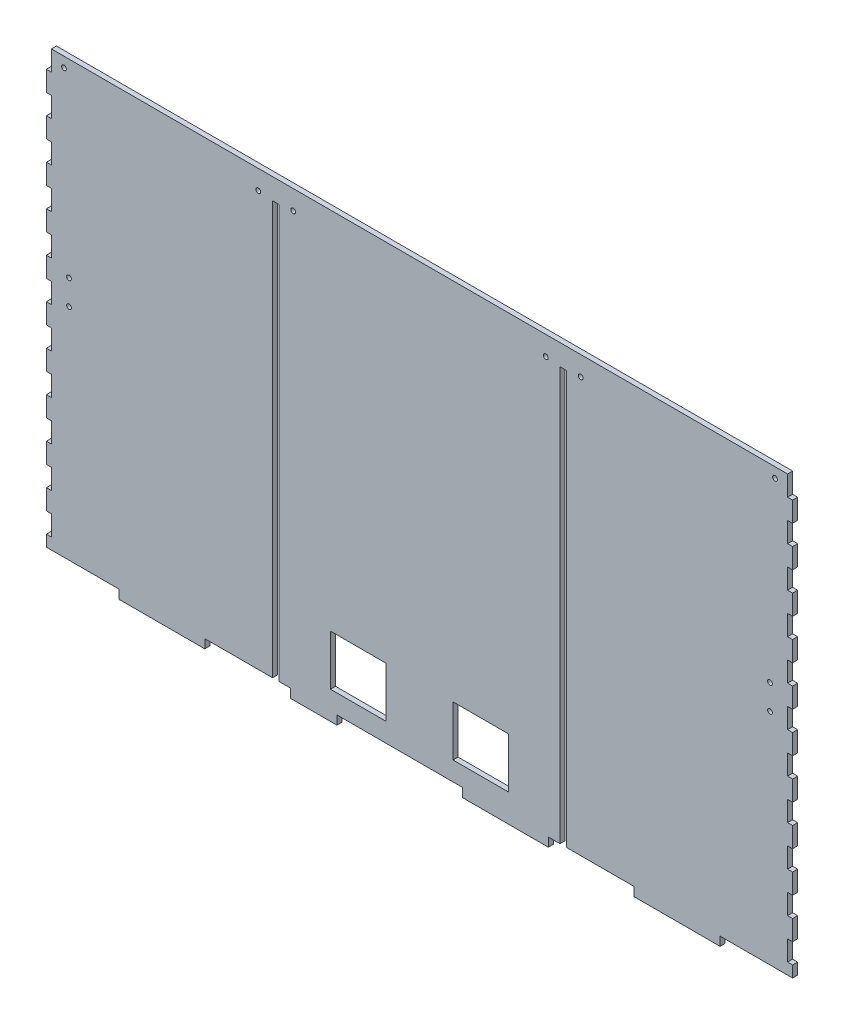
from build123d import *

# Parameters (mm, degrees)
SKETCH1_W                    = 3.175
SKETCH1_H                    = 12.7
MAIN_EXTRUDE_DEPTH           = 3.175
SKETCH8_R                    = 1.5
SKETCH8_W                    = 3.175
SKETCH8_H                    = 31.877
MOUNT_HOLES_DEPTH            = 4.175
SKETCH3_W                    = 4
SKETCH3_H                    = 260.604
DOOR_SLOTS_DEPTH             = 10
SKETCH10_R                   = 1.5
DOOR_GUIDE_MOUNT_HOLES_DEPTH = 4.175
SKETCH12_R                   = 1.5
EXTENSION_CLIP_HOLES_DEPTH   = 4.175
EXTENSION_CENTER_CUT_DEPTH   = 4.175
SKETCH17_W                   = 35
SKETCH17_H                   = 31.75
SKETCH17_W_2                 = 24.976666667
SKETCH17_H_2                 = 5.588
NOSEPOKEHOLES_DEPTH          = 10


with BuildPart() as part:
    # Sketch1 → Main Extrude (new body)
    with BuildSketch(Plane.XY):
        Polygon((-243.84, -134.112), (-189.653333333, -134.112), (-189.653333333, -139.7), (-135.466666667, -139.7), (-135.466666667, -134.112), (-81.28, -134.112), (-81.28, -139.7), (-27.093333333, -139.7), (-27.093333333, -134.112), (27.093333333, -134.112), (27.093333333, -139.7), (81.28, -139.7), (81.28, -134.112), (135.466666667, -134.112), (135.466666667, -139.7), (189.653333333, -139.7), (189.653333333, -134.112), (243.84, -134.112), (243.84, -139.7), (298.026666667, -139.7), (298.026666667, -134.112), (352.213333333, -134.112), (352.213333333, -139.7), (406.4, -139.7), (406.4, 139.7), (381, 139.7), (381, 127), (377.825, 127), (377.825, 139.7), (-377.825, 139.7), (-377.825, 127), (-381, 127), (-381, 139.7), (-406.4, 139.7), (-406.4, -139.7), (-352.213333333, -139.7), (-352.213333333, -134.112), (-298.026666667, -134.112), (-298.026666667, -139.7), (-243.84, -139.7), align=None)
        with Locations((-379.4125, -120.65)):
            Rectangle(SKETCH1_W, SKETCH1_H, mode=Mode.SUBTRACT)
        with Locations((-379.4125, -95.25)):
            Rectangle(SKETCH1_W, SKETCH1_H, mode=Mode.SUBTRACT)
        with Locations((379.4125, 82.55)):
            Rectangle(SKETCH1_W, SKETCH1_H, mode=Mode.SUBTRACT)
        with Locations((379.4125, 57.15)):
            Rectangle(SKETCH1_W, SKETCH1_H, mode=Mode.SUBTRACT)
        with Locations((379.4125, 31.75)):
            Rectangle(SKETCH1_W, SKETCH1_H, mode=Mode.SUBTRACT)
        with Locations((379.4125, 6.35)):
            Rectangle(SKETCH1_W, SKETCH1_H, mode=Mode.SUBTRACT)
        with Locations((379.4125, -19.05)):
            Rectangle(SKETCH1_W, SKETCH1_H, mode=Mode.SUBTRACT)
        with Locations((379.4125, -44.45)):
            Rectangle(SKETCH1_W, SKETCH1_H, mode=Mode.SUBTRACT)
        with Locations((379.4125, -69.85)):
            Rectangle(SKETCH1_W, SKETCH1_H, mode=Mode.SUBTRACT)
        with Locations((379.4125, -95.25)):
            Rectangle(SKETCH1_W, SKETCH1_H, mode=Mode.SUBTRACT)
        with Locations((379.4125, -120.65)):
            Rectangle(SKETCH1_W, SKETCH1_H, mode=Mode.SUBTRACT)
        with Locations((-379.4125, -69.85)):
            Rectangle(SKETCH1_W, SKETCH1_H, mode=Mode.SUBTRACT)
        with Locations((-379.4125, -44.45)):
            Rectangle(SKETCH1_W, SKETCH1_H, mode=Mode.SUBTRACT)
        with Locations((-379.4125, -19.05)):
            Rectangle(SKETCH1_W, SKETCH1_H, mode=Mode.SUBTRACT)
        with Locations((-379.4125, 6.35)):
            Rectangle(SKETCH1_W, SKETCH1_H, mode=Mode.SUBTRACT)
        with Locations((-379.4125, 31.75)):
            Rectangle(SKETCH1_W, SKETCH1_H, mode=Mode.SUBTRACT)
        with Locations((-379.4125, 57.15)):
            Rectangle(SKETCH1_W, SKETCH1_H, mode=Mode.SUBTRACT)
        with Locations((-379.4125, 82.55)):
            Rectangle(SKETCH1_W, SKETCH1_H, mode=Mode.SUBTRACT)
        with Locations((-379.4125, 107.95)):
            Rectangle(SKETCH1_W, SKETCH1_H, mode=Mode.SUBTRACT)
        with Locations((379.4125, 107.95)):
            Rectangle(SKETCH1_W, SKETCH1_H, mode=Mode.SUBTRACT)
    extrude(amount=MAIN_EXTRUDE_DEPTH)

    # Sketch8 → Mount Holes (cut, through all)
    with BuildSketch(Plane.XY.offset(3.175)):
        with Locations((-393.7, -120.65)):
            Circle(SKETCH8_R)
        with Locations((393.7, -120.65)):
            Circle(SKETCH8_R)
        with Locations((-382.5875, 12.319)):
            Rectangle(SKETCH8_W, SKETCH8_H)
        with Locations((382.5875, 12.319)):
            Rectangle(SKETCH8_W, SKETCH8_H)
    extrude(amount=-MOUNT_HOLES_DEPTH, mode=Mode.SUBTRACT)

    # Sketch3 → Door Slots (cut)
    with BuildSketch(Plane.XY.offset(3.175)):
        with Locations((-90.678, -3.81)):
            Rectangle(SKETCH3_W, SKETCH3_H)
        with Locations((90.678, -3.81)):
            Rectangle(SKETCH3_W, SKETCH3_H)
    extrude(amount=-DOOR_SLOTS_DEPTH, mode=Mode.SUBTRACT)

    # Sketch10 → Door Guide Mount Holes (cut, through all)
    with BuildSketch(Plane.XY.offset(3.175)):
        with Locations((-101.678, 127.492)):
            Circle(SKETCH10_R)
        with Locations((-79.678, 127.492)):
            Circle(SKETCH10_R)
        with Locations((79.678, 127.492)):
            Circle(SKETCH10_R)
        with Locations((101.678, 127.492)):
            Circle(SKETCH10_R)
    extrude(amount=-DOOR_GUIDE_MOUNT_HOLES_DEPTH, mode=Mode.SUBTRACT)

    # Sketch12 → Extension Clip Holes (cut, through all)
    with BuildSketch(Plane.XY.offset(3.175)):
        with Locations((-246.507, 20.193)):
            Circle(SKETCH12_R)
        with Locations((-246.507, 4.445)):
            Circle(SKETCH12_R)
        with Locations((-221.107, 4.445)):
            Circle(SKETCH12_R)
        with Locations((-221.107, 20.193)):
            Circle(SKETCH12_R)
        with Locations((-243.332, 133.35)):
            Circle(SKETCH12_R)
        with Locations((-224.282, 133.35)):
            Circle(SKETCH12_R)
        with Locations((224.282, 133.35)):
            Circle(SKETCH12_R)
        with Locations((243.332, 133.35)):
            Circle(SKETCH12_R)
        with Locations((221.107, 20.193)):
            Circle(SKETCH12_R)
        with Locations((221.107, 4.445)):
            Circle(SKETCH12_R)
        with Locations((246.507, 4.445)):
            Circle(SKETCH12_R)
        with Locations((246.507, 20.193)):
            Circle(SKETCH12_R)
    extrude(amount=-EXTENSION_CLIP_HOLES_DEPTH, mode=Mode.SUBTRACT)

    # Sketch11_3 → Extension Center Cut (cut, through all)
    with BuildSketch(Plane.XY.offset(3.175)):
        Polygon((-232.2195, 127), (-232.2195, 139.7), (-406.4, 139.7), (-406.4, -139.7), (-235.3945, -139.7), (-235.3945, -127), (-232.2195, -127), (-232.2195, -114.3), (-235.3945, -114.3), (-235.3945, -101.6), (-232.2195, -101.6), (-232.2195, -88.9), (-235.3945, -88.9), (-235.3945, -76.2), (-232.2195, -76.2), (-232.2195, -63.5), (-235.3945, -63.5), (-235.3945, -50.8), (-232.2195, -50.8), (-232.2195, -38.1), (-235.3945, -38.1), (-235.3945, -25.4), (-232.2195, -25.4), (-232.2195, -12.7), (-235.3945, -12.7), (-235.3945, 0), (-232.2195, 0), (-232.2195, 12.7), (-235.3945, 12.7), (-235.3945, 25.4), (-232.2195, 25.4), (-232.2195, 38.1), (-235.3945, 38.1), (-235.3945, 50.8), (-232.2195, 50.8), (-232.2195, 63.5), (-235.3945, 63.5), (-235.3945, 76.2), (-232.2195, 76.2), (-232.2195, 88.9), (-235.3945, 88.9), (-235.3945, 101.6), (-232.2195, 101.6), (-232.2195, 114.3), (-235.3945, 114.3), (-235.3945, 127), align=None)
        Polygon((406.4, 139.7), (232.2195, 139.7), (232.2195, 127), (235.3945, 127), (235.3945, 114.3), (232.2195, 114.3), (232.2195, 101.6), (235.3945, 101.6), (235.3945, 88.9), (232.2195, 88.9), (232.2195, 76.2), (235.3945, 76.2), (235.3945, 63.5), (232.2195, 63.5), (232.2195, 50.8), (235.3945, 50.8), (235.3945, 38.1), (232.2195, 38.1), (232.2195, 25.4), (235.3945, 25.4), (235.3945, 12.7), (232.2195, 12.7), (232.2195, 0), (235.3945, 0), (235.3945, -12.7), (232.2195, -12.7), (232.2195, -25.4), (235.3945, -25.4), (235.3945, -38.1), (232.2195, -38.1), (232.2195, -50.8), (235.3945, -50.8), (235.3945, -63.5), (232.2195, -63.5), (232.2195, -76.2), (235.3945, -76.2), (235.3945, -88.9), (232.2195, -88.9), (232.2195, -101.6), (235.3945, -101.6), (235.3945, -114.3), (232.2195, -114.3), (232.2195, -127), (235.3945, -127), (235.3945, -139.7), (406.4, -139.7), align=None)
    extrude(amount=-EXTENSION_CENTER_CUT_DEPTH, mode=Mode.SUBTRACT)

    # Sketch17 → Nosepokeholes (cut)
    with BuildSketch(Plane.XY.offset(3.175)):
        with Locations((38.678, -106.237)):
            Rectangle(SKETCH17_W, SKETCH17_H)
        with Locations((-38.678, -106.237)):
            Rectangle(SKETCH17_W, SKETCH17_H)
        with Locations((-39.581666666, -136.906)):
            Rectangle(SKETCH17_W_2, SKETCH17_H_2)
    extrude(amount=-NOSEPOKEHOLES_DEPTH, mode=Mode.SUBTRACT)


solid = part.part
